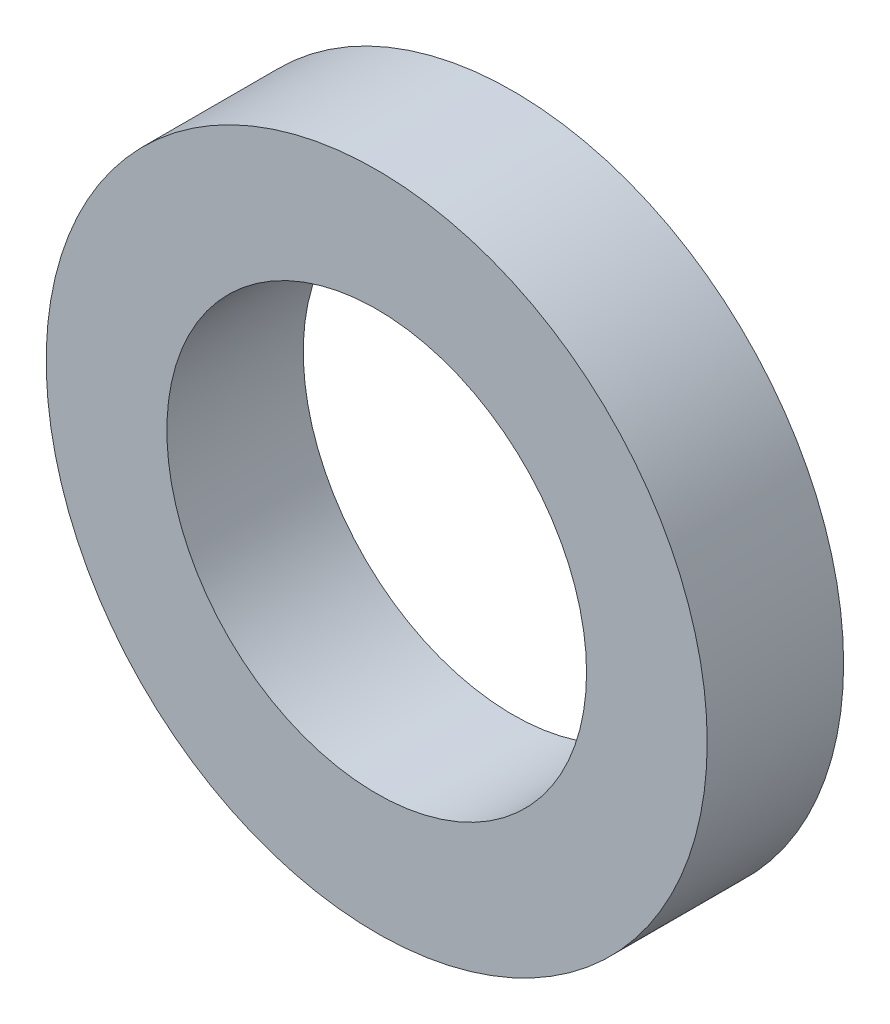
from build123d import *

# Parameters (mm, degrees)
SKETCH1_R           = 12.6
SKETCH1_R_2         = 8
BOSS_EXTRUDE1_DEPTH = 5.2


with BuildPart() as part:
    # Sketch1 → Boss-Extrude1 (new body)
    with BuildSketch(Plane.XY):
        Circle(SKETCH1_R)
        Circle(SKETCH1_R_2, mode=Mode.SUBTRACT)
    extrude(amount=BOSS_EXTRUDE1_DEPTH)


solid = part.part
